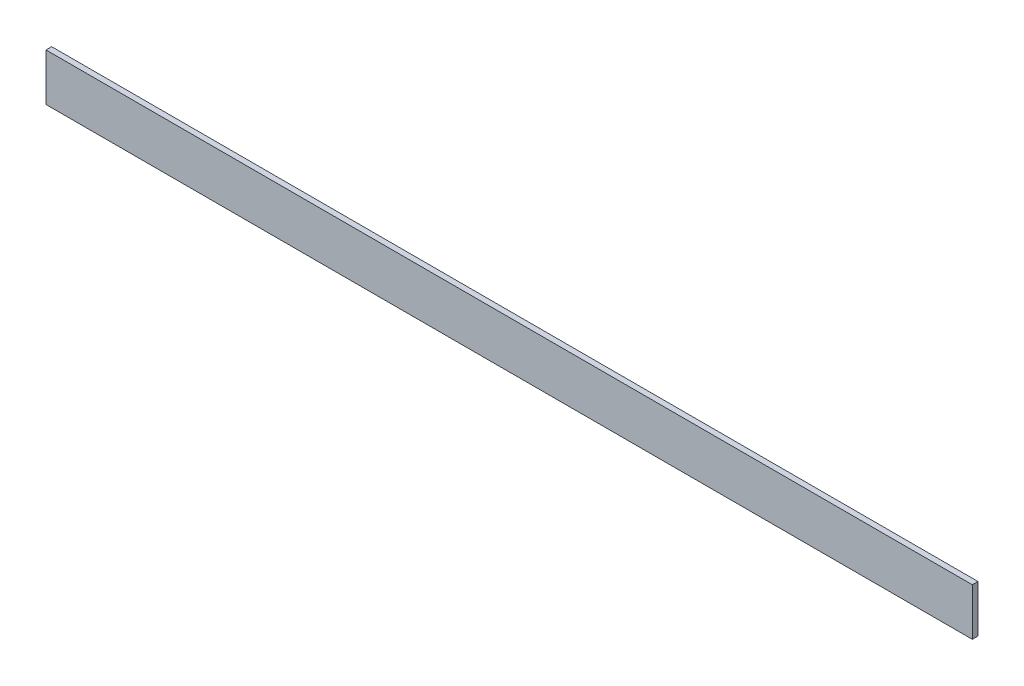
from build123d import *

# Parameters (mm, degrees)
EXTRUDE_1_DEPTH     = 490
SKETCH_2_W          = 22
SKETCH_2_H          = 22
CUT_EXTRUDE_1_DEPTH = 26


with BuildPart() as part:
    # Эскиз1 → Вытянуть-Тонкостенный1 (new body)
    with BuildSketch(Plane(origin=(0, 0, 0), x_dir=(0, 0, -1), z_dir=(1, 0, 0))):
        Polygon((0, 25), (0, 0), (25, 0), (25, 3), (3, 3), (3, 25), align=None)
    extrude(amount=EXTRUDE_1_DEPTH)

    # Эскиз2 → Вырез-Вытянуть1 (cut, through all)
    with BuildSketch(Plane.XZ):
        with Locations((11, -14)):
            Rectangle(SKETCH_2_W, SKETCH_2_H)
        with Locations((479, -14)):
            Rectangle(SKETCH_2_W, SKETCH_2_H)
    extrude(amount=-CUT_EXTRUDE_1_DEPTH, mode=Mode.SUBTRACT)


solid = part.part
